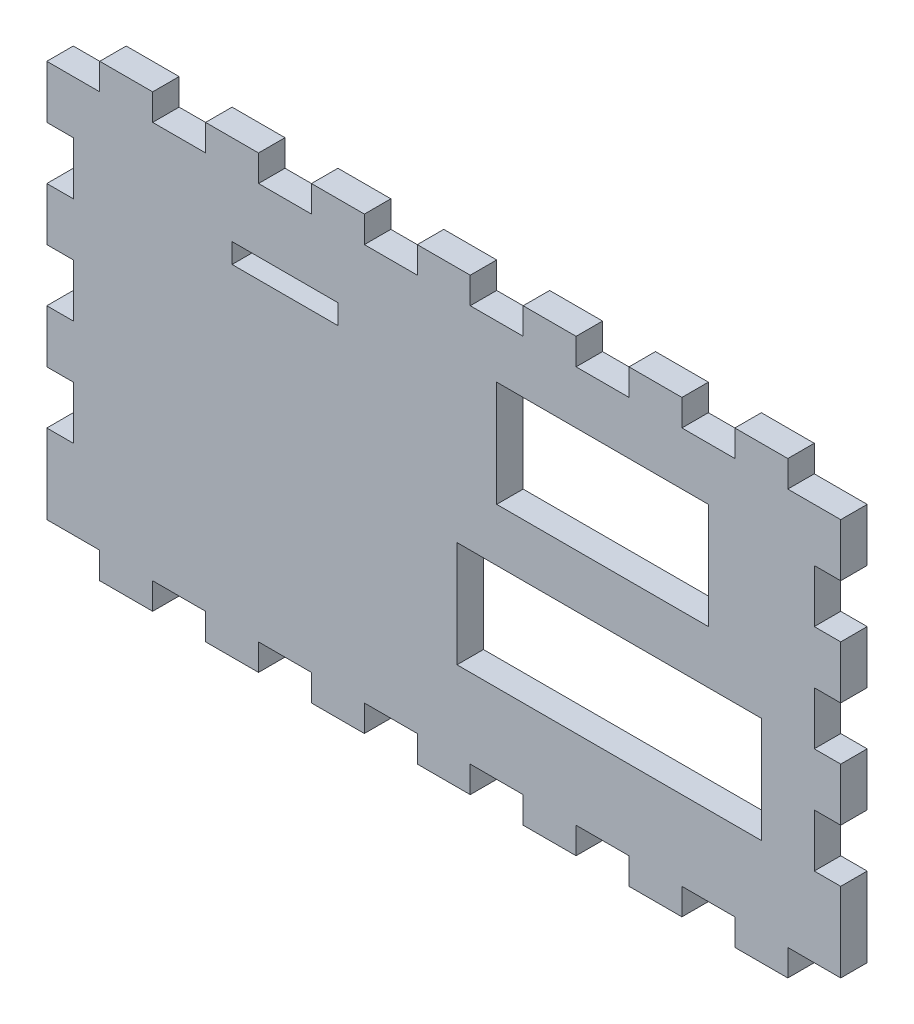
from build123d import *

# Parameters (mm, degrees)
SKETCH1_W               = 190.5
SKETCH1_H               = 107.95
BOSS_EXTRUDE1_DEPTH     = 6.35
SKETCH2_W               = 12.7
SKETCH2_H               = 6.35
CUT_EXTRUDE1_DEPTH      = 7.35
LPATTERN1_COUNT         = 8
LPATTERN1_PITCH         = 25.4
MIRROR1_COPY_1_SKETCH_W = 12.7
MIRROR1_COPY_1_SKETCH_H = 6.35
MIRROR1_COPY_1_DEPTH    = 7.35
MIRROR1_COPY_2_SKETCH_W = 12.7
MIRROR1_COPY_2_SKETCH_H = 6.35
MIRROR1_COPY_2_DEPTH    = 7.35
MIRROR1_COPY_3_SKETCH_W = 12.7
MIRROR1_COPY_3_SKETCH_H = 6.35
MIRROR1_COPY_3_DEPTH    = 7.35
MIRROR1_COPY_4_SKETCH_W = 12.7
MIRROR1_COPY_4_SKETCH_H = 6.35
MIRROR1_COPY_4_DEPTH    = 7.35
MIRROR1_COPY_5_SKETCH_W = 12.7
MIRROR1_COPY_5_SKETCH_H = 6.35
MIRROR1_COPY_5_DEPTH    = 7.35
MIRROR1_COPY_6_SKETCH_W = 12.7
MIRROR1_COPY_6_SKETCH_H = 6.35
MIRROR1_COPY_6_DEPTH    = 7.35
MIRROR1_COPY_7_SKETCH_W = 12.7
MIRROR1_COPY_7_SKETCH_H = 6.35
MIRROR1_COPY_7_DEPTH    = 7.35
SKETCH3_W               = 6.35
SKETCH3_H               = 12.7
CUT_EXTRUDE2_DEPTH      = 7.35
LPATTERN2_COUNT         = 3
LPATTERN2_PITCH         = 25.4
MIRROR2_COPY_1_SKETCH_W = 6.35
MIRROR2_COPY_1_SKETCH_H = 12.7
MIRROR2_COPY_1_DEPTH    = 7.35
MIRROR2_COPY_2_SKETCH_W = 6.35
MIRROR2_COPY_2_SKETCH_H = 12.7
MIRROR2_COPY_2_DEPTH    = 7.35
SKETCH4_W               = 25.4
SKETCH4_H               = 4.7625
CUT_EXTRUDE3_DEPTH      = 7.35
SKETCH5_W               = 73.025
SKETCH5_H               = 25.4
CUT_EXTRUDE4_DEPTH      = 7.35
SKETCH6_W               = 50.8
SKETCH6_H               = 25.4
CUT_EXTRUDE5_DEPTH      = 7.35


with BuildPart() as part:
    # Sketch1 → Boss-Extrude1 (new body)
    with BuildSketch(Plane.XY):
        Rectangle(SKETCH1_W, SKETCH1_H)
    extrude(amount=BOSS_EXTRUDE1_DEPTH)

    # Sketch2 → Cut-Extrude1 (cut, through all)
    with BuildSketch(Plane.XY.offset(6.35)):
        with Locations((-88.9, -50.8)):
            Rectangle(SKETCH2_W, SKETCH2_H)
    cut_extrude1 = extrude(amount=-CUT_EXTRUDE1_DEPTH, mode=Mode.SUBTRACT)

    # LPattern1: Cut-Extrude1 ×8
    with Locations(*[(i * LPATTERN1_PITCH, 0, 0) for i in range(1, LPATTERN1_COUNT)]):
        add(cut_extrude1, mode=Mode.SUBTRACT)

    # Mirror1: Cut-Extrude1 across plane
    add(cut_extrude1.mirror(Plane.ZX), mode=Mode.SUBTRACT)

    # Mirror1 copy 1 sketch → Mirror1 copy 1 (cut, through all)
    with BuildSketch(Plane(origin=(25.4, 0, 6.35), x_dir=(1, 0, 0), z_dir=(0, 0, 1))):
        with Locations((-88.9, 50.8)):
            Rectangle(MIRROR1_COPY_1_SKETCH_W, MIRROR1_COPY_1_SKETCH_H)
    extrude(amount=-MIRROR1_COPY_1_DEPTH, mode=Mode.SUBTRACT)

    # Mirror1 copy 2 sketch → Mirror1 copy 2 (cut, through all)
    with BuildSketch(Plane(origin=(50.8, 0, 6.35), x_dir=(1, 0, 0), z_dir=(0, 0, 1))):
        with Locations((-88.9, 50.8)):
            Rectangle(MIRROR1_COPY_2_SKETCH_W, MIRROR1_COPY_2_SKETCH_H)
    extrude(amount=-MIRROR1_COPY_2_DEPTH, mode=Mode.SUBTRACT)

    # Mirror1 copy 3 sketch → Mirror1 copy 3 (cut, through all)
    with BuildSketch(Plane(origin=(76.2, 0, 6.35), x_dir=(1, 0, 0), z_dir=(0, 0, 1))):
        with Locations((-88.9, 50.8)):
            Rectangle(MIRROR1_COPY_3_SKETCH_W, MIRROR1_COPY_3_SKETCH_H)
    extrude(amount=-MIRROR1_COPY_3_DEPTH, mode=Mode.SUBTRACT)

    # Mirror1 copy 4 sketch → Mirror1 copy 4 (cut, through all)
    with BuildSketch(Plane(origin=(101.6, 0, 6.35), x_dir=(1, 0, 0), z_dir=(0, 0, 1))):
        with Locations((-88.9, 50.8)):
            Rectangle(MIRROR1_COPY_4_SKETCH_W, MIRROR1_COPY_4_SKETCH_H)
    extrude(amount=-MIRROR1_COPY_4_DEPTH, mode=Mode.SUBTRACT)

    # Mirror1 copy 5 sketch → Mirror1 copy 5 (cut, through all)
    with BuildSketch(Plane(origin=(127, 0, 6.35), x_dir=(1, 0, 0), z_dir=(0, 0, 1))):
        with Locations((-88.9, 50.8)):
            Rectangle(MIRROR1_COPY_5_SKETCH_W, MIRROR1_COPY_5_SKETCH_H)
    extrude(amount=-MIRROR1_COPY_5_DEPTH, mode=Mode.SUBTRACT)

    # Mirror1 copy 6 sketch → Mirror1 copy 6 (cut, through all)
    with BuildSketch(Plane(origin=(152.4, 0, 6.35), x_dir=(1, 0, 0), z_dir=(0, 0, 1))):
        with Locations((-88.9, 50.8)):
            Rectangle(MIRROR1_COPY_6_SKETCH_W, MIRROR1_COPY_6_SKETCH_H)
    extrude(amount=-MIRROR1_COPY_6_DEPTH, mode=Mode.SUBTRACT)

    # Mirror1 copy 7 sketch → Mirror1 copy 7 (cut, through all)
    with BuildSketch(Plane(origin=(177.8, 0, 6.35), x_dir=(1, 0, 0), z_dir=(0, 0, 1))):
        with Locations((-88.9, 50.8)):
            Rectangle(MIRROR1_COPY_7_SKETCH_W, MIRROR1_COPY_7_SKETCH_H)
    extrude(amount=-MIRROR1_COPY_7_DEPTH, mode=Mode.SUBTRACT)

    # Sketch3 → Cut-Extrude2 (cut, through all)
    with BuildSketch(Plane.XY.offset(6.35)):
        with Locations((-92.075, 28.575)):
            Rectangle(SKETCH3_W, SKETCH3_H)
    cut_extrude2 = extrude(amount=-CUT_EXTRUDE2_DEPTH, mode=Mode.SUBTRACT)

    # LPattern2: Cut-Extrude2 ×3
    with Locations(*[(0, -i * LPATTERN2_PITCH, 0) for i in range(1, LPATTERN2_COUNT)]):
        add(cut_extrude2, mode=Mode.SUBTRACT)

    # Mirror2: Cut-Extrude2 across plane
    add(cut_extrude2.mirror(Plane(origin=(0, 0, 0), x_dir=(0, 0, 1), z_dir=(1, 0, 0))), mode=Mode.SUBTRACT)

    # Mirror2 copy 1 sketch → Mirror2 copy 1 (cut, through all)
    with BuildSketch(Plane(origin=(0, -25.4, 6.35), x_dir=(-1, 0, 0), z_dir=(0, 0, 1))):
        with Locations((-92.075, -28.575)):
            Rectangle(MIRROR2_COPY_1_SKETCH_W, MIRROR2_COPY_1_SKETCH_H)
    extrude(amount=-MIRROR2_COPY_1_DEPTH, mode=Mode.SUBTRACT)

    # Mirror2 copy 2 sketch → Mirror2 copy 2 (cut, through all)
    with BuildSketch(Plane(origin=(0, -50.8, 6.35), x_dir=(-1, 0, 0), z_dir=(0, 0, 1))):
        with Locations((-92.075, -28.575)):
            Rectangle(MIRROR2_COPY_2_SKETCH_W, MIRROR2_COPY_2_SKETCH_H)
    extrude(amount=-MIRROR2_COPY_2_DEPTH, mode=Mode.SUBTRACT)

    # Sketch4 → Cut-Extrude3 (cut, through all)
    with BuildSketch(Plane.XY.offset(6.35)):
        with Locations((-38.1, 30.00375)):
            Rectangle(SKETCH4_W, SKETCH4_H)
    extrude(amount=-CUT_EXTRUDE3_DEPTH, mode=Mode.SUBTRACT)

    # Sketch5 → Cut-Extrude4 (cut, through all)
    with BuildSketch(Plane.XY.offset(6.35)):
        with Locations((39.6875, -15.875)):
            Rectangle(SKETCH5_W, SKETCH5_H)
    extrude(amount=-CUT_EXTRUDE4_DEPTH, mode=Mode.SUBTRACT)

    # Sketch6 → Cut-Extrude5 (cut, through all)
    with BuildSketch(Plane.XY.offset(6.35)):
        with Locations((38.1, 22.225)):
            Rectangle(SKETCH6_W, SKETCH6_H)
    extrude(amount=-CUT_EXTRUDE5_DEPTH, mode=Mode.SUBTRACT)


solid = part.part
